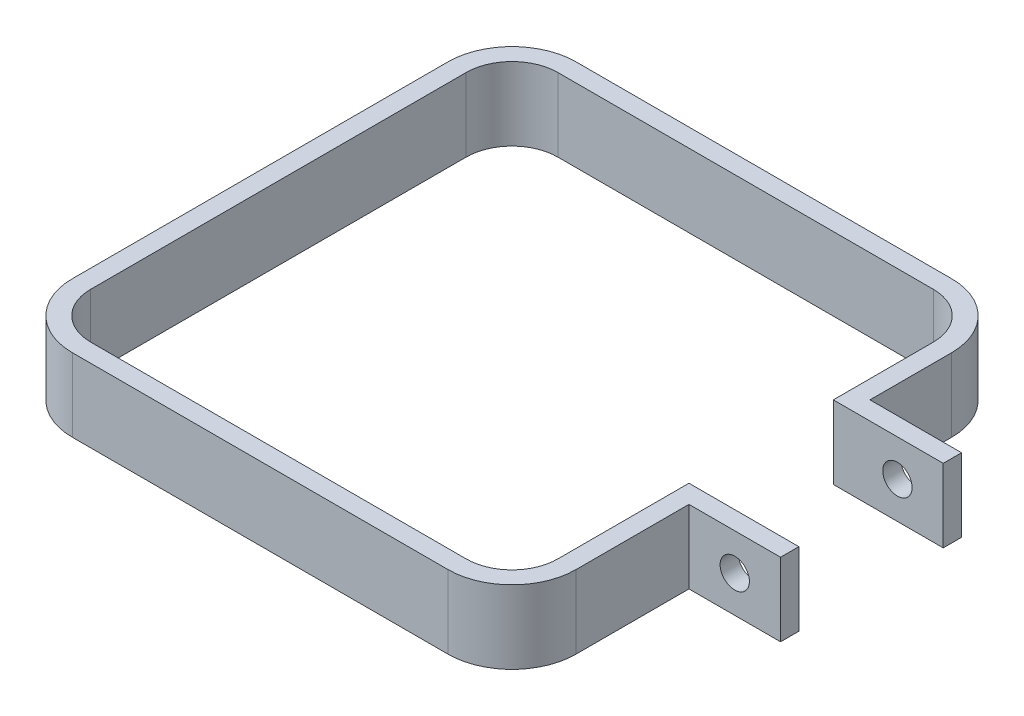
from build123d import *

# Parameters (mm, degrees)
BOSS_EXTRUDE1_DEPTH = 8
SKETCH2_R           = 1.6
CUT_EXTRUDE1_DEPTH  = 37.084183


with BuildPart() as part:
    # Sketch1 → Boss-Extrude1 (new body)
    with BuildSketch(Plane(origin=(0, 0, 0), x_dir=(1, 0, 0), z_dir=(0, 1, 0))):
        with BuildLine():
            Line((-20.5, 27.5), (20.5, 27.5))
            ThreePointArc((20.5, 27.5), (25.449747468, 25.449747468), (27.5, 20.5))
            Line((27.5, 20.5), (27.5, 11.5841835))
            Line((27.5, 11.5841835), (37.5, 11.5841835))
            Line((37.5, 11.5841835), (37.5, 9.5841835))
            Line((37.5, 9.5841835), (27.5, 9.5841835))
            Line((27.5, 9.5841835), (25.5, 9.5841835))
            Line((25.5, 9.5841835), (25.5, 20.5))
            ThreePointArc((25.5, 20.5), (24.035533906, 24.035533906), (20.5, 25.5))
            Line((20.5, 25.5), (-20.5, 25.5))
            ThreePointArc((-20.5, 25.5), (-24.035533906, 24.035533906), (-25.5, 20.5))
            Line((-25.5, 20.5), (-25.5, -20.5))
            ThreePointArc((-25.5, -20.5), (-24.035533906, -24.035533906), (-20.5, -25.5))
            Line((-20.5, -25.5), (20.5, -25.5))
            ThreePointArc((20.5, -25.5), (24.035533906, -24.035533906), (25.5, -20.5))
            Line((25.5, -20.5), (25.5, -6.177954833))
            Line((25.5, -6.177954833), (27.5, -6.177954833))
            Line((27.5, -6.177954833), (37.5, -6.177954833))
            Line((37.5, -6.177954833), (37.5, -8.177954833))
            Line((37.5, -8.177954833), (27.5, -8.177954833))
            Line((27.5, -8.177954833), (27.5, -20.5))
            ThreePointArc((27.5, -20.5), (25.449747468, -25.449747468), (20.5, -27.5))
            Line((20.5, -27.5), (-20.5, -27.5))
            ThreePointArc((-20.5, -27.5), (-25.449747468, -25.449747468), (-27.5, -20.5))
            Line((-27.5, -20.5), (-27.5, 20.5))
            ThreePointArc((-27.5, 20.5), (-25.449747468, 25.449747468), (-20.5, 27.5))
        make_face()
    extrude(amount=BOSS_EXTRUDE1_DEPTH)

    # Sketch2 → Cut-Extrude1 (cut)
    with BuildSketch(Plane(origin=(0, 0, -11.5841835), x_dir=(-1, 0, 0), z_dir=(0, 0, -1))):
        with Locations((-32.5, 4)):
            Circle(SKETCH2_R)
    extrude(amount=-CUT_EXTRUDE1_DEPTH, mode=Mode.SUBTRACT)


solid = part.part
